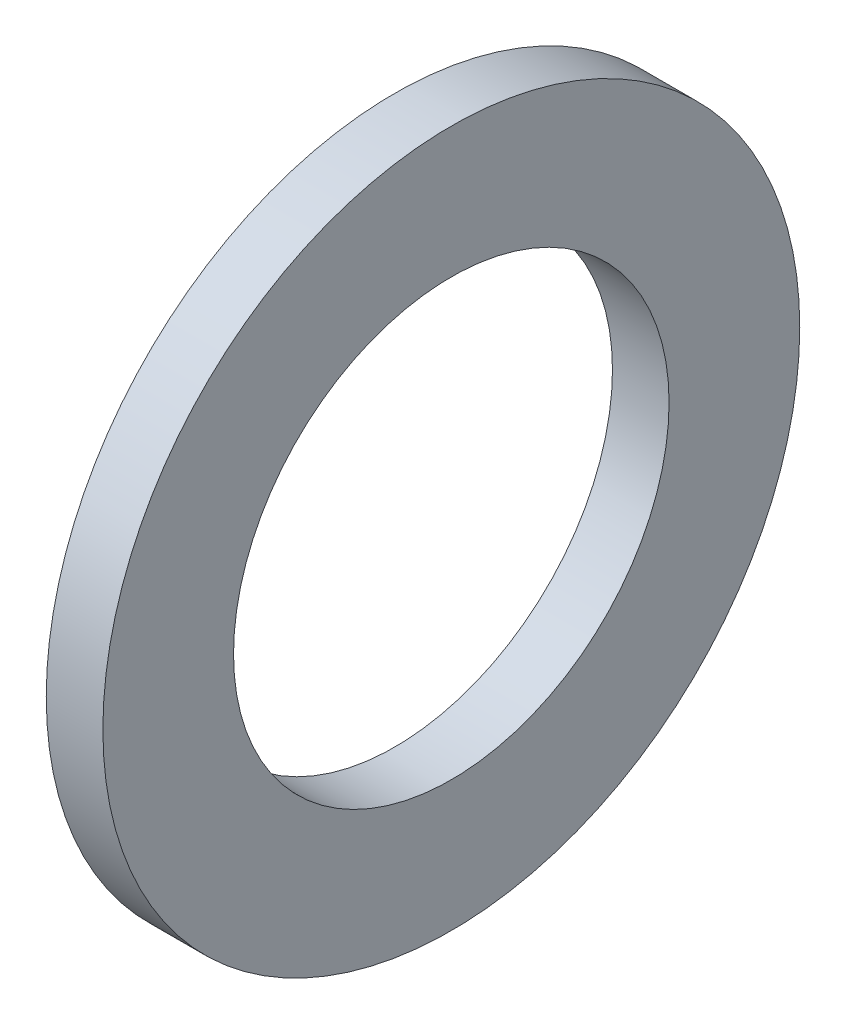
from build123d import *

# Parameters (mm, degrees)
SKETCH1_R           = 10.16
SKETCH1_R_2         = 6.35
BOSS_EXTRUDE1_DEPTH = 1.651


with BuildPart() as part:
    # Sketch1 → Boss-Extrude1 (new body)
    with BuildSketch(Plane(origin=(0, 0, 0), x_dir=(0, 0, -1), z_dir=(1, 0, 0))):
        Circle(SKETCH1_R)
        Circle(SKETCH1_R_2, mode=Mode.SUBTRACT)
    extrude(amount=BOSS_EXTRUDE1_DEPTH)


solid = part.part
